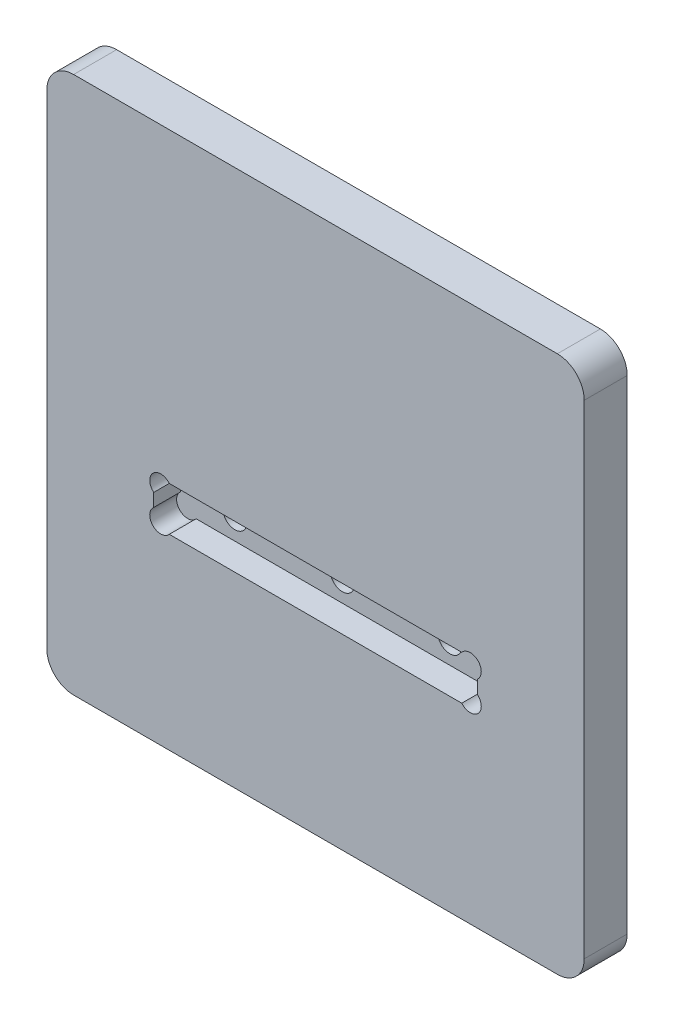
from build123d import *

# Parameters (mm, degrees)
ESQUISSE1_W                  = 100
ESQUISSE1_H                  = 100
BOSS_EXTRU_1_DEPTH           = 8
ESQUISSE2_W                  = 60.2
ESQUISSE2_H                  = 8.2
ENL_V_MAT_EXTRU_1_DEPTH      = 5
CONG_1_R                     = 5
ENL_V_MAT_EXTRU_2_DEPTH      = 5
ESQUISSE4_R                  = 2.25
ENL_V_MAT_EXTRU_3_DEPTH      = 6
ENL_V_MAT_EXTRU_3_DEPTH_BACK = 4


with BuildPart() as part:
    # Esquisse1 → Boss.-Extru.1 (new body)
    with BuildSketch(Plane.XY):
        with Locations((50, 50)):
            Rectangle(ESQUISSE1_W, ESQUISSE1_H)
    extrude(amount=BOSS_EXTRU_1_DEPTH)

    # Esquisse2 → Enlèv. mat.-Extru.1 (cut)
    with BuildSketch(Plane.XY.offset(8)):
        with Locations((50, 38.9)):
            Rectangle(ESQUISSE2_W, ESQUISSE2_H)
    extrude(amount=-ENL_V_MAT_EXTRU_1_DEPTH, mode=Mode.SUBTRACT)

    # Congé1
    cong_1_edges = [part.edges().sort_by_distance(p)[0] for p in [
        (0, 100, 4),
        (100, 100, 4),
        (100, 0, 4),
        (0, 0, 4),
    ]]
    fillet(cong_1_edges, radius=CONG_1_R)

    # Esquisse3 → Enlèv. mat.-Extru.2 (cut)
    with BuildSketch(Plane.XY.offset(8)):
        with BuildLine():
            Line((77.213483043, 43), (80.1, 40.113483043))
            ThreePointArc((80.1, 40.113483043), (80.241421356, 43.141421356), (77.213483043, 43))
        make_face()
        with BuildLine():
            Line((77.213483043, 34.8), (80.1, 37.686516957))
            ThreePointArc((80.1, 37.686516957), (80.241421356, 34.658578644), (77.213483043, 34.8))
        make_face()
        with BuildLine():
            Line((22.786516957, 34.8), (19.9, 37.686516957))
            ThreePointArc((19.9, 37.686516957), (19.758578644, 34.658578644), (22.786516957, 34.8))
        make_face()
        with BuildLine():
            Line((22.786516957, 43), (19.9, 40.113483043))
            ThreePointArc((19.9, 40.113483043), (19.758578644, 43.141421356), (22.786516957, 43))
        make_face()
    extrude(amount=-ENL_V_MAT_EXTRU_2_DEPTH, mode=Mode.SUBTRACT)

    # Esquisse4 → Enlèv. mat.-Extru.3 (cut, two sides)
    with BuildSketch(Plane.XY.offset(3)) as enl_v_mat_extru_3_sk:
        with Locations((50, 38.9)):
            Circle(ESQUISSE4_R)
        with Locations((70, 38.9)):
            Circle(ESQUISSE4_R)
        with Locations((30, 38.9)):
            Circle(ESQUISSE4_R)
    extrude(amount=ENL_V_MAT_EXTRU_3_DEPTH, mode=Mode.SUBTRACT)
    extrude(enl_v_mat_extru_3_sk.sketch, amount=-ENL_V_MAT_EXTRU_3_DEPTH_BACK, mode=Mode.SUBTRACT)


solid = part.part
